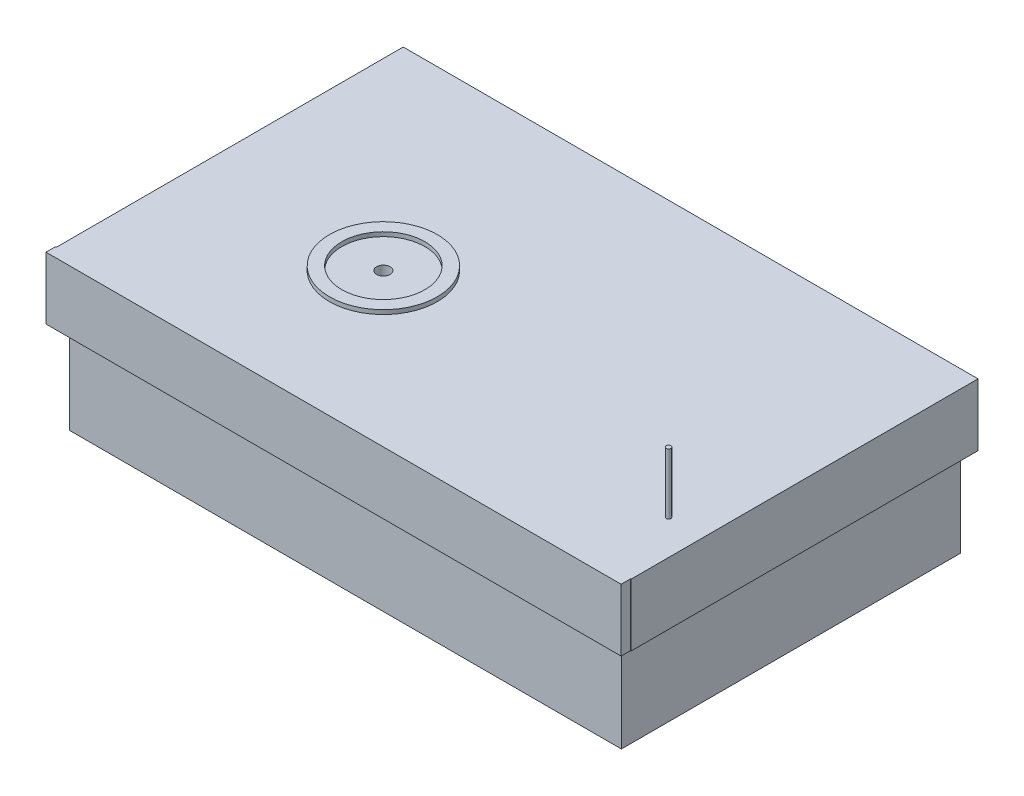
from build123d import *

# Parameters (mm, degrees)
CROQUIS1_W                   = 270
CROQUIS1_H                   = 240
SALIENTE_EXTRUIR1_DEPTH      = 30
CROQUIS1_W_2                 = 116.5
SALIENTE_EXTRUIR1_2_DEPTH    = 30
SALIENTE_EXTRUIR3_DEPTH      = 63.5
CROQUIS3_W                   = 406.759820342
CROQUIS3_H                   = 44.054315541
SALIENTE_EXTRUIR4_DEPTH      = 245.5
CROQUIS4_R                   = 38.153863336
CROQUIS4_R_2                 = 29.41561916
SALIENTE_EXTRUIR5_DEPTH      = 3
CROQUIS5_R                   = 4.7645
CORTAR_EXTRUIR1_DEPTH        = 142
CROQUIS6_W                   = 6.655343447
CROQUIS6_H                   = 44.054315541
SALIENTE_EXTRUIR6_DEPTH      = 294
SALIENTE_EXTRUIR6_DEPTH_BACK = 113
CROQUIS7_R                   = 1.651
SALIENTE_EXTRUIR8_DEPTH      = 112
SALIENTE_EXTRUIR8_DEPTH_BACK = 2
CROQUIS8_W                   = 3.302
CROQUIS8_H                   = 24.988896413
CORTAR_EXTRUIR2_DEPTH        = 112


with BuildPart() as part:
    # Croquis1 → Saliente-Extruir1 (new body)
    with BuildSketch(Plane(origin=(0, 0, 0), x_dir=(1, 0, 0), z_dir=(0, 1, 0))):
        with Locations((32.193078438, 120)):
            Rectangle(CROQUIS1_W, CROQUIS1_H)
    extrude(amount=SALIENTE_EXTRUIR1_DEPTH)



with BuildPart() as body_2:
    # Croquis1 → Saliente-Extruir1 2 (new body)
    with BuildSketch(Plane(origin=(0, 0, 0), x_dir=(1, 0, 0), z_dir=(0, 1, 0))):
        with Locations((229.288362697, 120)):
            Rectangle(CROQUIS1_W_2, CROQUIS1_H)
    extrude(amount=SALIENTE_EXTRUIR1_2_DEPTH)


with BuildPart() as part_1:
    add(part.part)

    add(body_2.part)  # Saliente-Extruir3 merges body 2
    # Croquis2 → Saliente-Extruir3 (add)
    with BuildSketch(Plane(origin=(0, 0, 0), x_dir=(1, 0, 0), z_dir=(0, 1, 0))):
        Polygon((-102.861944812, 0), (287.538362697, 0), (287.538362697, 240), (-102.806921562, 240), align=None)
    extrude(amount=-SALIENTE_EXTRUIR3_DEPTH)

    # Croquis3 → Saliente-Extruir4 (add)
    with BuildSketch(Plane.XY):
        with Locations((91.027758877, 22.027157771)):
            Rectangle(CROQUIS3_W, CROQUIS3_H)
    extrude(amount=-SALIENTE_EXTRUIR4_DEPTH)

    # Croquis4 → Saliente-Extruir5 (add)
    with BuildSketch(Plane(origin=(0, 44.054315541, 0), x_dir=(1, 0, 0), z_dir=(0, 1, 0))):
        with Locations((17.647848706, 101.450529821)):
            Circle(CROQUIS4_R)
        with Locations((17.647848706, 101.450529821)):
            Circle(CROQUIS4_R_2, mode=Mode.SUBTRACT)
    extrude(amount=SALIENTE_EXTRUIR5_DEPTH)

    # Croquis5 → Cortar-Extruir1 (cut)
    with BuildSketch(Plane(origin=(0, 0, 0), x_dir=(1, 0, 0), z_dir=(0, 1, 0))):
        with Locations((17.647848706, 101.450529821)):
            Circle(CROQUIS5_R)
    extrude(amount=CORTAR_EXTRUIR1_DEPTH, mode=Mode.SUBTRACT)

    # Croquis6 → Saliente-Extruir6 (add, two sides)
    with BuildSketch(Plane(origin=(0, 0, 0), x_dir=(0, 0, -1), z_dir=(1, 0, 0))) as saliente_extruir6_sk:
        with Locations((-3.327671724, 22.027157771)):
            Rectangle(CROQUIS6_W, CROQUIS6_H)
    extrude(amount=SALIENTE_EXTRUIR6_DEPTH)
    extrude(saliente_extruir6_sk.sketch, amount=-SALIENTE_EXTRUIR6_DEPTH_BACK)

    # Croquis7 → Saliente-Extruir8 (add, two sides)
    with BuildSketch(Plane(origin=(0, 0, 0), x_dir=(1, 0, 0), z_dir=(0, 1, 0))) as saliente_extruir8_sk:
        with Locations((269.705344772, 51.231276753)):
            Circle(CROQUIS7_R)
    extrude(amount=SALIENTE_EXTRUIR8_DEPTH)
    extrude(saliente_extruir8_sk.sketch, amount=-SALIENTE_EXTRUIR8_DEPTH_BACK)

    # Croquis8 → Cortar-Extruir2 (cut)
    with BuildSketch(Plane.XY):
        with Locations((269.705344772, 99.505551794)):
            Rectangle(CROQUIS8_W, CROQUIS8_H)
    extrude(amount=-CORTAR_EXTRUIR2_DEPTH, mode=Mode.SUBTRACT)


solid = part_1.part
